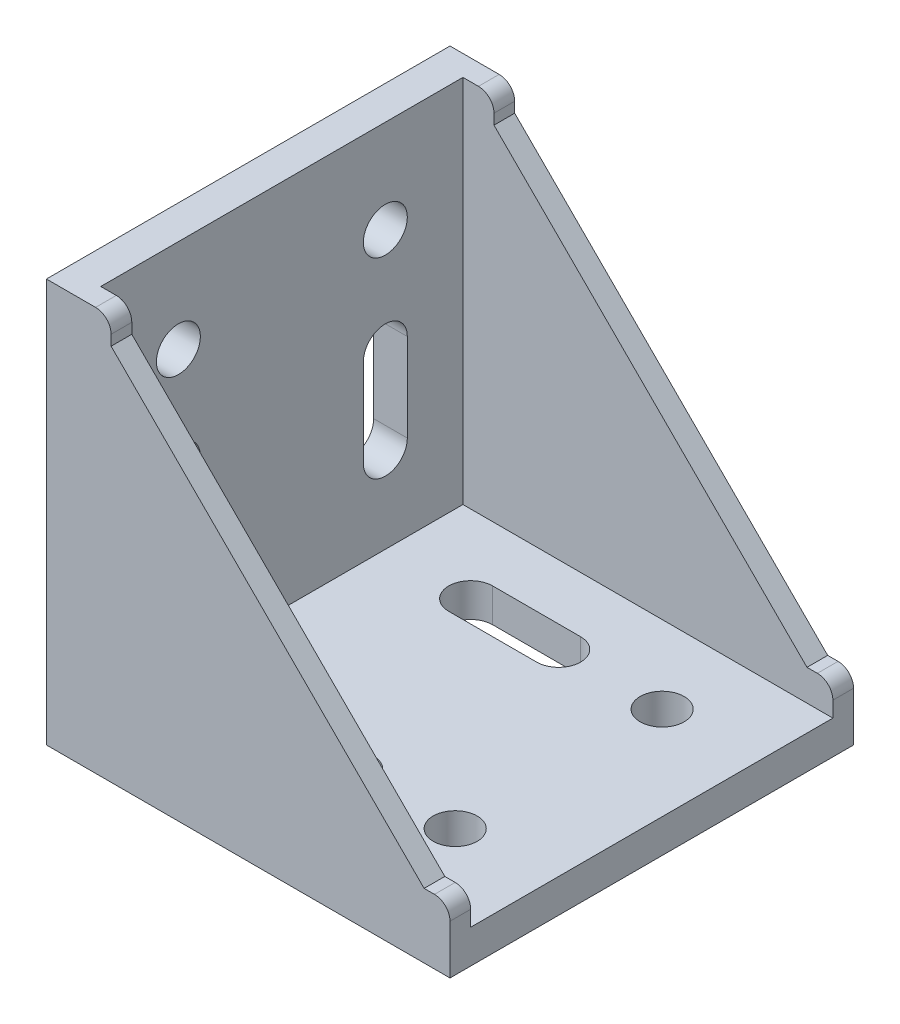
from build123d import *

# Parameters (mm, degrees)
EXTRUDE_1_DEPTH     = 39
EXTRUDE_2_DEPTH     = 4
SKETCH_3_R          = 4.25
CUT_EXTRUDE_1_DEPTH = 7.5
SKETCH_4_W          = 3
SKETCH_4_H          = 8
EXTRUDE_3_DEPTH     = 2.5


with BuildPart() as part:
    # Эскиз1 → Бобышка-Вытянуть1 (new body, symmetric)
    with BuildSketch(Plane.XY):
        Polygon((0, 78), (0, 0), (78, 0), (78, 6.5), (6.5, 6.5), (6.5, 78), align=None)
    extrude(amount=EXTRUDE_1_DEPTH, both=True)

    # Эскиз2 → Бобышка-Вытянуть2 (add)
    with BuildSketch(Plane.XY.offset(39)):
        with BuildLine():
            Line((78, 6.5), (6.5, 6.5))
            Line((6.5, 6.5), (6.5, 78))
            Line((6.5, 78), (9.5, 78))
            ThreePointArc((9.5, 78), (11.621320344, 77.121320344), (12.5, 75))
            Line((12.5, 75), (12.5, 73))
            Line((12.5, 73), (73, 12.5))
            Line((73, 12.5), (75, 12.5))
            ThreePointArc((75, 12.5), (77.121320344, 11.621320344), (78, 9.5))
            Line((78, 9.5), (78, 6.5))
        make_face()
    extrude_2 = extrude(amount=-EXTRUDE_2_DEPTH)

    # Зеркальное отражение2: Бобышка-Вытянуть2 across plane
    add(extrude_2.mirror(Plane.XY))

    # Эскиз3 → Вырез-Вытянуть1 (cut, through all)
    with BuildSketch(Plane(origin=(0, 6.5, 0), x_dir=(1, 0, 0), z_dir=(0, 1, 0))):
        with Locations(Location((60, -20, 0), (0, 0, 270))):  # turned: the seam where the file's is
            Circle(SKETCH_3_R)
        with Locations(Location((60, 20, 0), (0, 0, 90))):  # turned: the seam where the file's is
            Circle(SKETCH_3_R)
        with BuildLine():
            Line((23, -15.75), (40, -15.75))
            ThreePointArc((40, -15.75), (44.25, -20), (40, -24.25))
            Line((40, -24.25), (23, -24.25))
            ThreePointArc((23, -24.25), (18.75, -20), (23, -15.75))
        make_face()
        with BuildLine():
            Line((23, 15.75), (40, 15.75))
            ThreePointArc((40, 15.75), (44.25, 20), (40, 24.25))
            Line((40, 24.25), (23, 24.25))
            ThreePointArc((23, 24.25), (18.75, 20), (23, 15.75))
        make_face()
    cut_extrude_1 = extrude(amount=-CUT_EXTRUDE_1_DEPTH, mode=Mode.SUBTRACT)

    # Эскиз4 → Бобышка-Вытянуть3 (add)
    with BuildSketch(Plane.XZ):
        with Locations((4.5, -20)):
            Rectangle(SKETCH_4_W, SKETCH_4_H)
        with Locations((73.5, -20)):
            Rectangle(SKETCH_4_W, SKETCH_4_H)
        with Locations((73.5, 20)):
            Rectangle(SKETCH_4_W, SKETCH_4_H)
        with Locations((4.5, 20)):
            Rectangle(SKETCH_4_W, SKETCH_4_H)
    extrude_3 = extrude(amount=EXTRUDE_3_DEPTH)

    # Зеркальное отражение3: Вырез-Вытянуть1, Бобышка-Вытянуть3 across plane
    add(cut_extrude_1.mirror(Plane(origin=(0, 0, 0), x_dir=(0, 0, 1), z_dir=(-0.707106781, 0.707106781, 0))), mode=Mode.SUBTRACT)
    add(extrude_3.mirror(Plane(origin=(0, 0, 0), x_dir=(0, 0, 1), z_dir=(-0.707106781, 0.707106781, 0))))


solid = part.part
